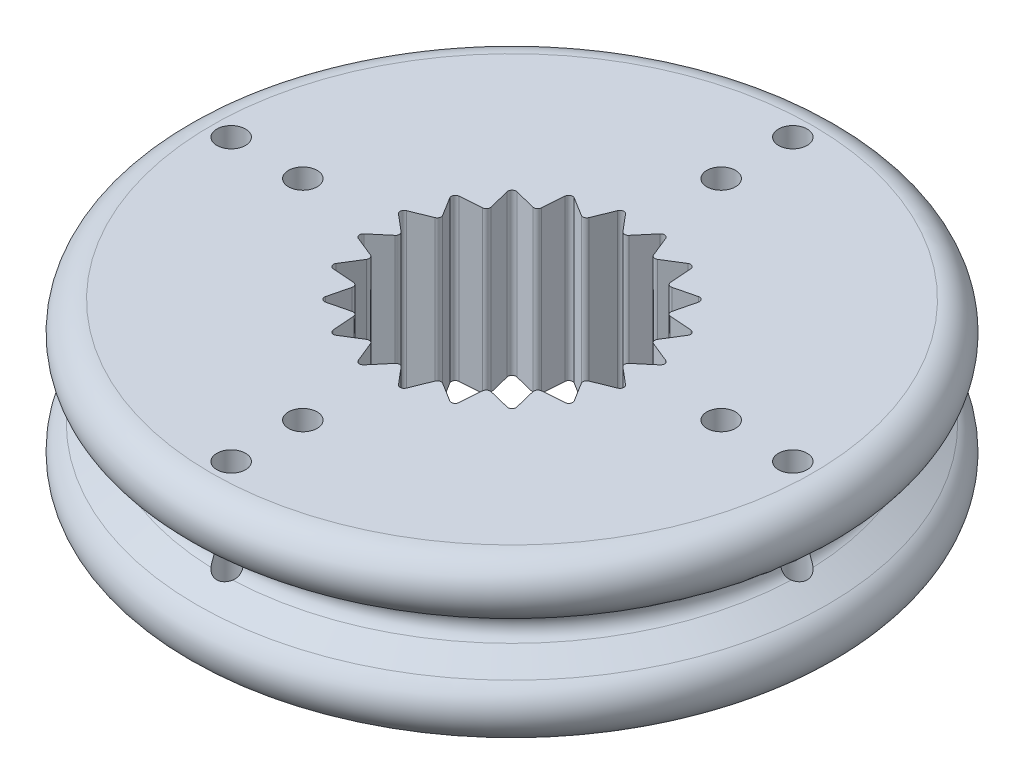
from build123d import *

# Parameters (mm, degrees)
CUT_EXTRUDE1_START  = -3.65
SKETCH2_R           = 0.25
CUT_EXTRUDE1_DEPTH  = 10
CUT_EXTRUDE2_START  = -3.8000001
SKETCH3_R           = 0.25
CUT_EXTRUDE2_DEPTH  = 4.8000002
CIRPATTERN1_COUNT   = 4
BOSS_EXTRUDE1_DEPTH = 2.8
FILLET1_R           = 0.07


with BuildPart() as part:
    # Sketch1 → Revolve1 (revolve)
    with BuildSketch(Plane(origin=(0, 0, 0), x_dir=(0, 0, -1), z_dir=(1, 0, 0))):
        with BuildLine():
            Line((-2.4, 2.8), (-5.25, 2.8))
            ThreePointArc((-5.25, 2.8), (-5.732962913, 2.429409523), (-5.5, 1.866987298))
            Line((-5.5, 1.866987298), (-5.066154273, 1.616506351))
            ThreePointArc((-5.066154273, 1.616506351), (-4.941154273, 1.4), (-5.066154273, 1.183493649))
            Line((-5.066154273, 1.183493649), (-5.5, 0.933012702))
            ThreePointArc((-5.5, 0.933012702), (-5.732962913, 0.370590477), (-5.25, 0))
            Line((-5.25, 0), (-2.4, 0))
            Line((-2.4, 0), (-2.4, 2.8))
        make_face()
    revolve(axis=Axis((0, 0, 0), (0, 1, 0)))

    # Sketch2 → Cut-Extrude1 (cut)
    with BuildSketch(Plane(origin=(0, 0, 0), x_dir=(0, 0, -1), z_dir=(1, 0, 0)).offset(CUT_EXTRUDE1_START)):
        with Locations((0, 1.4)):
            Circle(SKETCH2_R)
    cut_extrude1 = extrude(amount=-CUT_EXTRUDE1_DEPTH, mode=Mode.SUBTRACT)

    # Sketch3 → Cut-Extrude2 (cut)
    with BuildSketch(Plane(origin=(0, 2.8, 0), x_dir=(1, 0, 0), z_dir=(0, 1, 0)).offset(CUT_EXTRUDE2_START)):
        with Locations((3.65, 0)):
            Circle(SKETCH3_R)
        with Locations((4.9, 0)):
            Circle(SKETCH3_R)
    cut_extrude2 = extrude(amount=CUT_EXTRUDE2_DEPTH, mode=Mode.SUBTRACT)

    # CirPattern1: Cut-Extrude1, Cut-Extrude2 ×4 about axis
    cirpattern1_axis = Axis((0, 0, 0), (0, 1, 0))
    for i in range(1, CIRPATTERN1_COUNT):
        add(cut_extrude1.rotate(cirpattern1_axis, i * 360 / CIRPATTERN1_COUNT), mode=Mode.SUBTRACT)
        add(cut_extrude2.rotate(cirpattern1_axis, i * 360 / CIRPATTERN1_COUNT), mode=Mode.SUBTRACT)

    # Sketch4 → Boss-Extrude1 (add)
    with BuildSketch(Plane(origin=(0, 0, 0), x_dir=(1, 0, 0), z_dir=(0, 1, 0))):
        with BuildLine():
            Line((1.830783794, 0.594857714), (2.370452017, 0.375442716))
            ThreePointArc((2.370452017, 0.375442716), (2.282535639, 0.741640786), (2.138415658, 1.089577199))
            Line((2.138415658, 1.089577199), (1.830783794, 0.594857714))
        make_face()
        with BuildLine():
            Line((1.925, 0), (2.370452017, -0.375442716))
            ThreePointArc((2.370452017, -0.375442716), (2.4, 0), (2.370452017, 0.375442716))
            Line((2.370452017, 0.375442716), (1.925, 0))
        make_face()
        with BuildLine():
            Line((1.830783794, -0.594857714), (2.138415658, -1.089577199))
            ThreePointArc((2.138415658, -1.089577199), (2.282535639, -0.741640786), (2.370452017, -0.375442716))
            Line((2.370452017, -0.375442716), (1.830783794, -0.594857714))
        make_face()
        with BuildLine():
            Line((1.557357714, -1.131486611), (1.697056275, -1.697056275))
            ThreePointArc((1.697056275, -1.697056275), (1.941640786, -1.410684606), (2.138415658, -1.089577199))
            Line((2.138415658, -1.089577199), (1.557357714, -1.131486611))
        make_face()
        with BuildLine():
            Line((0.594857714, -1.830783794), (0.375442716, -2.370452017))
            ThreePointArc((0.375442716, -2.370452017), (0.741640786, -2.282535639), (1.089577199, -2.138415658))
            Line((1.089577199, -2.138415658), (0.594857714, -1.830783794))
        make_face()
        with BuildLine():
            Line((0, -1.925), (-0.375442716, -2.370452017))
            ThreePointArc((-0.375442716, -2.370452017), (0, -2.4), (0.375442716, -2.370452017))
            Line((0.375442716, -2.370452017), (0, -1.925))
        make_face()
        with BuildLine():
            Line((1.557357714, 1.131486611), (2.138415658, 1.089577199))
            ThreePointArc((2.138415658, 1.089577199), (1.941640786, 1.410684606), (1.697056275, 1.697056275))
            Line((1.697056275, 1.697056275), (1.557357714, 1.131486611))
        make_face()
        with BuildLine():
            Line((1.131486611, 1.557357714), (1.697056275, 1.697056275))
            ThreePointArc((1.697056275, 1.697056275), (1.410684606, 1.941640786), (1.089577199, 2.138415658))
            Line((1.089577199, 2.138415658), (1.131486611, 1.557357714))
        make_face()
        with BuildLine():
            Line((0.594857714, 1.830783794), (1.089577199, 2.138415658))
            ThreePointArc((1.089577199, 2.138415658), (0.741640786, 2.282535639), (0.375442716, 2.370452017))
            Line((0.375442716, 2.370452017), (0.594857714, 1.830783794))
        make_face()
        with BuildLine():
            Line((0, 1.925), (0.375442716, 2.370452017))
            ThreePointArc((0.375442716, 2.370452017), (0, 2.4), (-0.375442716, 2.370452017))
            Line((-0.375442716, 2.370452017), (0, 1.925))
        make_face()
        with BuildLine():
            Line((-0.594857714, 1.830783794), (-0.375442716, 2.370452017))
            ThreePointArc((-0.375442716, 2.370452017), (-0.741640786, 2.282535639), (-1.089577199, 2.138415658))
            Line((-1.089577199, 2.138415658), (-0.594857714, 1.830783794))
        make_face()
        with BuildLine():
            Line((-1.131486611, 1.557357714), (-1.089577199, 2.138415658))
            ThreePointArc((-1.089577199, 2.138415658), (-1.410684606, 1.941640786), (-1.697056275, 1.697056275))
            Line((-1.697056275, 1.697056275), (-1.131486611, 1.557357714))
        make_face()
        with BuildLine():
            Line((-1.557357714, 1.131486611), (-1.697056275, 1.697056275))
            ThreePointArc((-1.697056275, 1.697056275), (-1.941640786, 1.410684606), (-2.138415658, 1.089577199))
            Line((-2.138415658, 1.089577199), (-1.557357714, 1.131486611))
        make_face()
        with BuildLine():
            Line((-1.830783794, 0.594857714), (-2.138415658, 1.089577199))
            ThreePointArc((-2.138415658, 1.089577199), (-2.282535639, 0.741640786), (-2.370452017, 0.375442716))
            Line((-2.370452017, 0.375442716), (-1.830783794, 0.594857714))
        make_face()
        with BuildLine():
            Line((-1.925, 0), (-2.370452017, 0.375442716))
            ThreePointArc((-2.370452017, 0.375442716), (-2.4, 0), (-2.370452017, -0.375442716))
            Line((-2.370452017, -0.375442716), (-1.925, 0))
        make_face()
        with BuildLine():
            Line((-1.830783794, -0.594857714), (-2.370452017, -0.375442716))
            ThreePointArc((-2.370452017, -0.375442716), (-2.282535639, -0.741640786), (-2.138415658, -1.089577199))
            Line((-2.138415658, -1.089577199), (-1.830783794, -0.594857714))
        make_face()
        with BuildLine():
            Line((-1.557357714, -1.131486611), (-2.138415658, -1.089577199))
            ThreePointArc((-2.138415658, -1.089577199), (-1.941640786, -1.410684606), (-1.697056275, -1.697056275))
            Line((-1.697056275, -1.697056275), (-1.557357714, -1.131486611))
        make_face()
        with BuildLine():
            Line((-1.131486611, -1.557357714), (-1.697056275, -1.697056275))
            ThreePointArc((-1.697056275, -1.697056275), (-1.410684606, -1.941640786), (-1.089577199, -2.138415658))
            Line((-1.089577199, -2.138415658), (-1.131486611, -1.557357714))
        make_face()
        with BuildLine():
            Line((-0.594857714, -1.830783794), (-1.089577199, -2.138415658))
            ThreePointArc((-1.089577199, -2.138415658), (-0.741640786, -2.282535639), (-0.375442716, -2.370452017))
            Line((-0.375442716, -2.370452017), (-0.594857714, -1.830783794))
        make_face()
        with BuildLine():
            Line((1.131486611, -1.557357714), (1.089577199, -2.138415658))
            ThreePointArc((1.089577199, -2.138415658), (1.410684606, -1.941640786), (1.697056275, -1.697056275))
            Line((1.697056275, -1.697056275), (1.131486611, -1.557357714))
        make_face()
    extrude(amount=BOSS_EXTRUDE1_DEPTH)

    # Fillet1
    fillet1_edges = [part.edges().sort_by_distance(p)[0] for p in [
        (1.925, 1.4, 0),
        (2.370452017, 1.4, -0.375442716),
        (1.830783794, 1.4, 0.594857714),
        (2.370452017, 1.4, 0.375442716),
        (1.557357714, 1.4, 1.131486611),
        (2.138415658, 1.4, 1.089577199),
        (0, 1.4, 1.925),
        (0.375442716, 1.4, 2.370452017),
        (1.557357714, 1.4, -1.131486611),
        (2.138415658, 1.4, -1.089577199),
        (1.131486611, 1.4, -1.557357714),
        (1.697056275, 1.4, -1.697056275),
        (0.594857714, 1.4, -1.830783794),
        (1.089577199, 1.4, -2.138415658),
        (0, 1.4, -1.925),
        (0.375442716, 1.4, -2.370452017),
        (-0.594857714, 1.4, -1.830783794),
        (-0.375442716, 1.4, -2.370452017),
        (-1.131486611, 1.4, -1.557357714),
        (-1.089577199, 1.4, -2.138415658),
        (-1.557357714, 1.4, -1.131486611),
        (-1.697056275, 1.4, -1.697056275),
        (-1.830783794, 1.4, -0.594857714),
        (-2.138415658, 1.4, -1.089577199),
        (-1.925, 1.4, 0),
        (-2.370452017, 1.4, -0.375442716),
        (-1.830783794, 1.4, 0.594857714),
        (-2.370452017, 1.4, 0.375442716),
        (-1.557357714, 1.4, 1.131486611),
        (-2.138415658, 1.4, 1.089577199),
        (-1.131486611, 1.4, 1.557357714),
        (-1.697056275, 1.4, 1.697056275),
        (-0.594857714, 1.4, 1.830783794),
        (-1.089577199, 1.4, 2.138415658),
        (-0.375442716, 1.4, 2.370452017),
        (0.594857714, 1.4, 1.830783794),
        (1.697056275, 1.4, 1.697056275),
        (1.089577199, 1.4, 2.138415658),
        (1.131486611, 1.4, 1.557357714),
        (1.830783794, 1.4, -0.594857714),
    ]]
    fillet(fillet1_edges, radius=FILLET1_R)


solid = part.part
